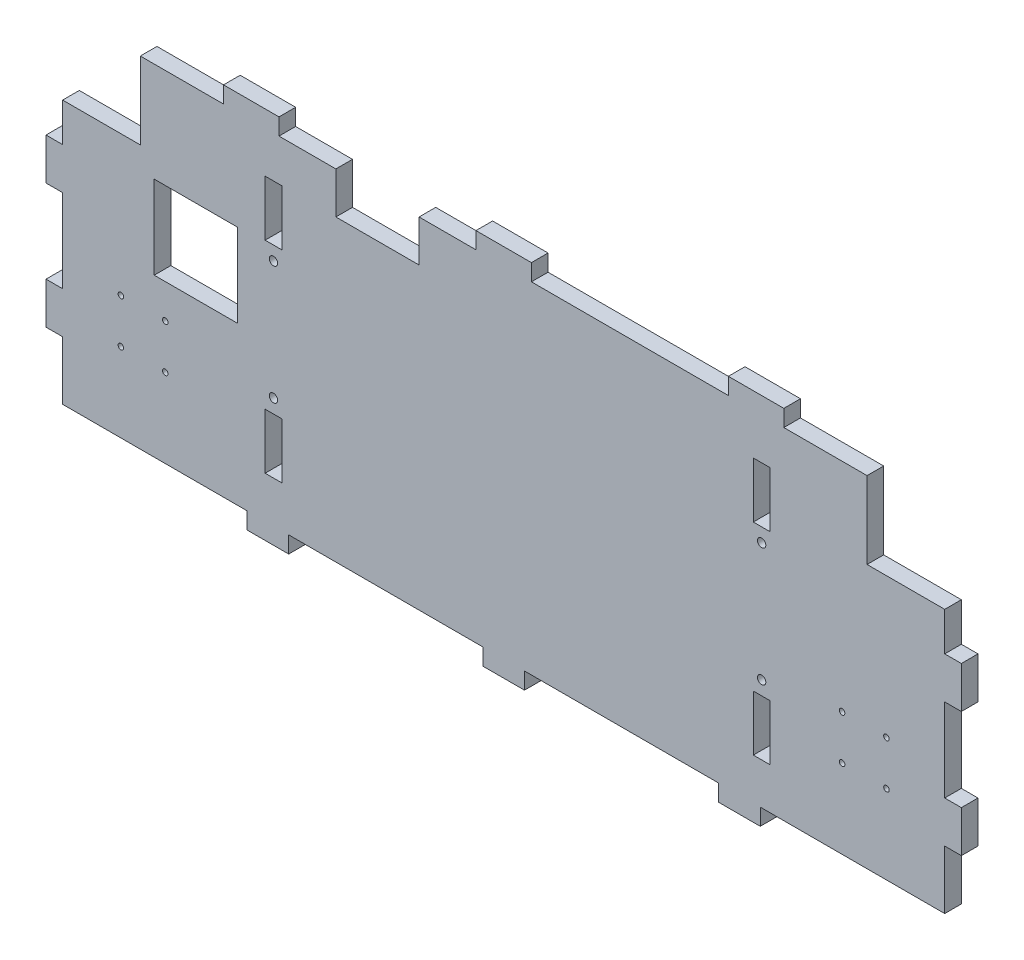
from build123d import *

# Parameters (mm, degrees)
ESQUISSE1_W             = 6
ESQUISSE1_H             = 20
ESQUISSE1_W_2           = 30
ESQUISSE1_H_2           = 30
BOSS_EXTRU_1_DEPTH      = 6
ESQUISSE2_W             = 15
ESQUISSE2_H             = 6
ESQUISSE2_W_2           = 6
ESQUISSE2_H_2           = 15
ESQUISSE2_W_3           = 20
BOSS_EXTRU_2_DEPTH      = 6
ESQUISSE3_R             = 1
ESQUISSE3_R_2           = 1.5
ENL_V_MAT_EXTRU_1_DEPTH = 6
ESQUISSE4_W             = 30
ESQUISSE4_H             = 15
ENL_V_MAT_EXTRU_2_DEPTH = 6


with BuildPart() as part:
    # Esquisse1 → Boss.-Extru.1 (new body)
    with BuildSketch(Plane.XY):
        Polygon((-159, 35), (-131, 35), (-131, 62.75), (131, 62.75), (131, 35), (159, 35), (159, -60), (-159, -60), align=None)
        with Locations((93, 37.75)):
            Rectangle(ESQUISSE1_W, ESQUISSE1_H, mode=Mode.SUBTRACT)
        with Locations((93, -35.01)):
            Rectangle(ESQUISSE1_W, ESQUISSE1_H, mode=Mode.SUBTRACT)
        with Locations((-83, 37.75)):
            Rectangle(ESQUISSE1_W, ESQUISSE1_H, mode=Mode.SUBTRACT)
        with Locations((-83, -35.01)):
            Rectangle(ESQUISSE1_W, ESQUISSE1_H, mode=Mode.SUBTRACT)
        with Locations((-110.986534361, 11.825583908)):
            Rectangle(ESQUISSE1_W_2, ESQUISSE1_H_2, mode=Mode.SUBTRACT)
    extrude(amount=BOSS_EXTRU_1_DEPTH)

    # Esquisse2 → Boss.-Extru.2 (add)
    with BuildSketch(Plane.XY.offset(6)):
        with Locations((-85, -63)):
            Rectangle(ESQUISSE2_W, ESQUISSE2_H)
        with Locations((0, -63)):
            Rectangle(ESQUISSE2_W, ESQUISSE2_H)
        with Locations((85, -63)):
            Rectangle(ESQUISSE2_W, ESQUISSE2_H)
        with Locations((-162, 13.59)):
            Rectangle(ESQUISSE2_W_2, ESQUISSE2_H_2)
        with Locations((-162, -31.41)):
            Rectangle(ESQUISSE2_W_2, ESQUISSE2_H_2)
        with Locations((162, -31.41)):
            Rectangle(ESQUISSE2_W_2, ESQUISSE2_H_2)
        with Locations((162, 13.59)):
            Rectangle(ESQUISSE2_W_2, ESQUISSE2_H_2)
        with Locations((91, 65.75)):
            Rectangle(ESQUISSE2_W_3, ESQUISSE2_H)
        with Locations((-91, 65.75)):
            Rectangle(ESQUISSE2_W_3, ESQUISSE2_H)
        with Locations((0, 65.75)):
            Rectangle(ESQUISSE2_W_3, ESQUISSE2_H)
    extrude(amount=-BOSS_EXTRU_2_DEPTH)

    # Esquisse3 → Enlèv. mat.-Extru.1 (cut)
    with BuildSketch(Plane(origin=(0, 0, 0), x_dir=(-1, 0, 0), z_dir=(0, 0, -1))):
        with Locations((138, -31.49)):
            Circle(ESQUISSE3_R)
        with Locations((138, -15.49)):
            Circle(ESQUISSE3_R)
        with Locations((122, -15.49)):
            Circle(ESQUISSE3_R)
        with Locations((122, -31.49)):
            Circle(ESQUISSE3_R)
        with Locations((-122, -31.49)):
            Circle(ESQUISSE3_R)
        with Locations((-122, -15.49)):
            Circle(ESQUISSE3_R)
        with Locations((-138, -15.49)):
            Circle(ESQUISSE3_R)
        with Locations((-138, -31.49)):
            Circle(ESQUISSE3_R)
        with Locations((83, 22.75)):
            Circle(ESQUISSE3_R_2)
        with Locations((83, -20.01)):
            Circle(ESQUISSE3_R_2)
        with Locations((-93, 22.75)):
            Circle(ESQUISSE3_R_2)
        with Locations((-93, -20.01)):
            Circle(ESQUISSE3_R_2)
    extrude(amount=-ENL_V_MAT_EXTRU_1_DEPTH, mode=Mode.SUBTRACT)

    # Esquisse4 → Enlèv. mat.-Extru.2 (cut)
    with BuildSketch(Plane(origin=(0, 0, 0), x_dir=(-1, 0, 0), z_dir=(0, 0, -1))):
        with Locations((45.5, 55.25)):
            Rectangle(ESQUISSE4_W, ESQUISSE4_H)
    extrude(amount=-ENL_V_MAT_EXTRU_2_DEPTH, mode=Mode.SUBTRACT)


solid = part.part
